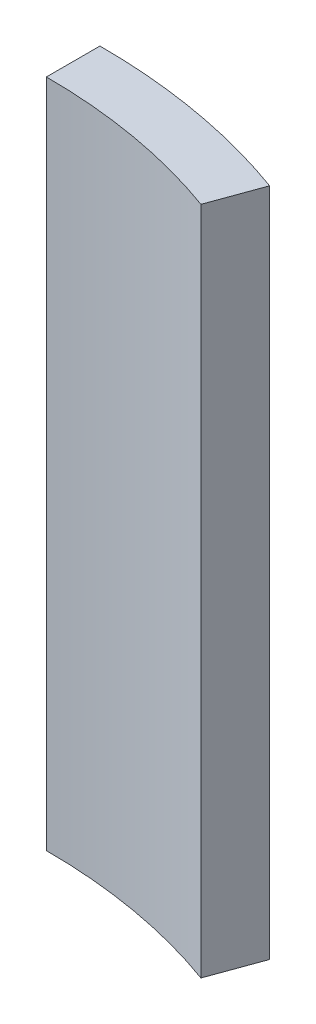
from build123d import *

# Parameters (mm, degrees)
BOSS_EXTRUDE1_DEPTH = 25


with BuildPart() as part:
    # Sketch1 → Boss-Extrude1 (new body)
    with BuildSketch(Plane(origin=(0, 0, 0), x_dir=(1, 0, 0), z_dir=(0, 1, 0))):
        with BuildLine():
            Line((7, 19.267848868), (7.682926829, 21.147639001))
            ThreePointArc((7.682926829, 21.147639001), (3.900520636, 22.159330738), (0, 22.5))
            Line((0, 22.5), (0, 20.5))
            ThreePointArc((0, 20.5), (3.553807691, 20.18961245), (7, 19.267848868))
        make_face()
    extrude(amount=BOSS_EXTRUDE1_DEPTH)


solid = part.part
